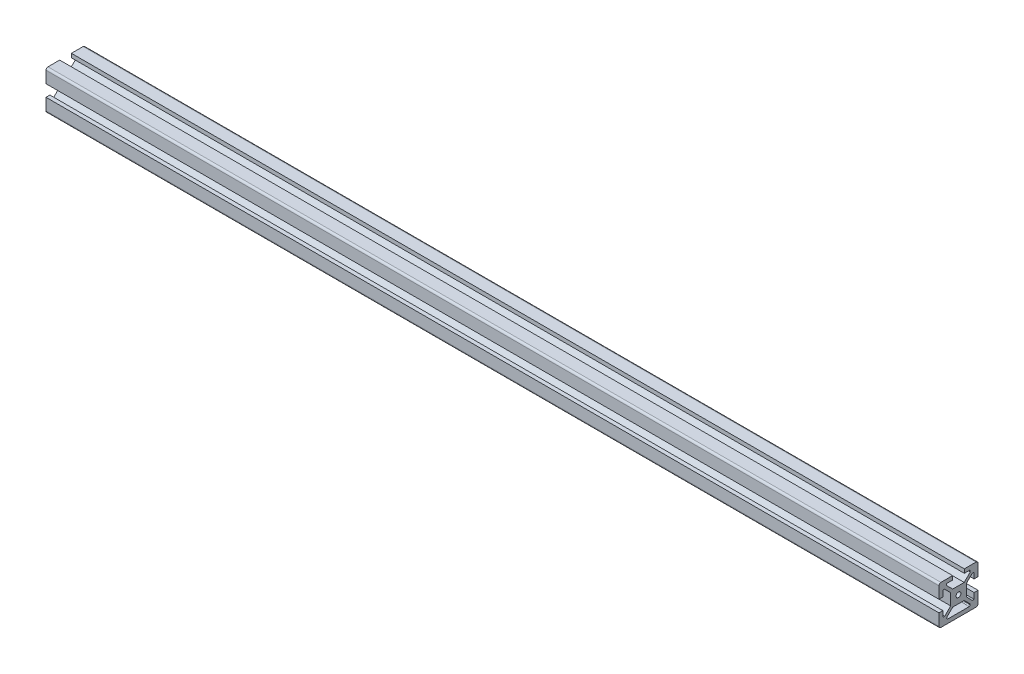
from build123d import *

# Parameters (mm, degrees)
SKETCH1_R           = 2.1
BOSS_EXTRUDE1_DEPTH = 457
SKETCH19_R          = 2.1
BOSS_EXTRUDE7_DEPTH = 6
TAPPED_HOLE6_D      = 2.5
TAPPED_HOLE6_DEPTH  = 6


with BuildPart() as part:
    # Sketch1 → Boss-Extrude1 (new body)
    with BuildSketch(Plane(origin=(0, 0, 0), x_dir=(0, 0, -1), z_dir=(1, 0, 0))):
        with BuildLine():
            Line((-10, 9), (-10, 3))
            Line((-10, 3), (-8, 3))
            Line((-8, 3), (-8, 6))
            Line((-8, 6), (-7.060660172, 6))
            Line((-7.060660172, 6), (-4, 2.939339828))
            Line((-4, 2.939339828), (-4, -2.939339828))
            Line((-4, -2.939339828), (-7.060660172, -6))
            Line((-7.060660172, -6), (-8, -6))
            Line((-8, -6), (-8, -3))
            Line((-8, -3), (-10, -3))
            Line((-10, -3), (-10, -9))
            ThreePointArc((-10, -9), (-9.707106781, -9.707106781), (-9, -10))
            Line((-9, -10), (9, -10))
            ThreePointArc((9, -10), (9.707106781, -9.707106781), (10, -9))
            Line((10, -9), (10, -3))
            Line((10, -3), (8, -3))
            Line((8, -3), (8, -6))
            Line((8, -6), (7.060660172, -6))
            Line((7.060660172, -6), (4, -2.939339828))
            Line((4, -2.939339828), (4, 2.939339828))
            Line((4, 2.939339828), (7.060660172, 6))
            Line((7.060660172, 6), (8, 6))
            Line((8, 6), (8, 3))
            Line((8, 3), (10, 3))
            Line((10, 3), (10, 9))
            ThreePointArc((10, 9), (9.707106781, 9.707106781), (9, 10))
            Line((9, 10), (3, 10))
            Line((3, 10), (3, 8))
            Line((3, 8), (6, 8))
            Line((6, 8), (6, 7.060660172))
            Line((6, 7.060660172), (2.939339828, 4))
            Line((2.939339828, 4), (-2.939339828, 4))
            Line((-2.939339828, 4), (-6, 7.060660172))
            Line((-6, 7.060660172), (-6, 8))
            Line((-6, 8), (-3, 8))
            Line((-3, 8), (-3, 10))
            Line((-3, 10), (-9, 10))
            ThreePointArc((-9, 10), (-9.707106781, 9.707106781), (-10, 9))
        make_face()
        Circle(SKETCH1_R, mode=Mode.SUBTRACT)
        with BuildLine():
            Line((-6, -7.267766953), (-6, -7.5))
            ThreePointArc((-6, -7.5), (-5.853553391, -7.853553391), (-5.5, -8))
            Line((-5.5, -8), (5.5, -8))
            ThreePointArc((5.5, -8), (5.853553391, -7.853553391), (6, -7.5))
            Line((6, -7.5), (6, -7.267766953))
            ThreePointArc((6, -7.267766953), (5.961939766, -7.076425237), (5.853553391, -6.914213562))
            Line((5.853553391, -6.914213562), (3.085786438, -4.146446609))
            ThreePointArc((3.085786438, -4.146446609), (2.923574763, -4.038060234), (2.732233047, -4))
            Line((2.732233047, -4), (-2.732233047, -4))
            ThreePointArc((-2.732233047, -4), (-2.923574763, -4.038060234), (-3.085786438, -4.146446609))
            Line((-3.085786438, -4.146446609), (-5.853553391, -6.914213562))
            ThreePointArc((-5.853553391, -6.914213562), (-5.961939766, -7.076425237), (-6, -7.267766953))
        make_face(mode=Mode.SUBTRACT)
    extrude(amount=BOSS_EXTRUDE1_DEPTH)

    # Sketch19 → Boss-Extrude7 (add)
    with BuildSketch(Plane(origin=(457, 0, 0), x_dir=(0, 0, -1), z_dir=(1, 0, 0))):
        Circle(SKETCH19_R)
    extrude(amount=-BOSS_EXTRUDE7_DEPTH)

    # Tapped Hole6
    with Locations(Plane(origin=(457, 0, -33.955827028), x_dir=(0, 0, 1), z_dir=(1, 0, 0))):
        with Locations((33.955827028, 0)):
            Hole(TAPPED_HOLE6_D / 2, depth=TAPPED_HOLE6_DEPTH)


solid = part.part
